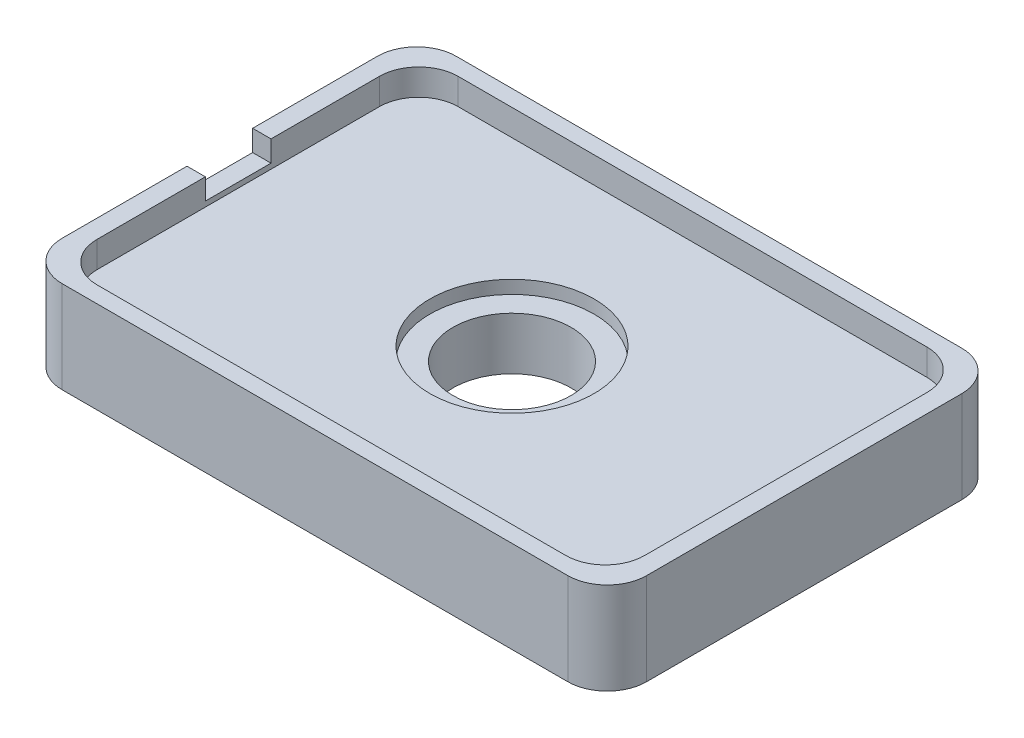
from build123d import *

# Parameters (mm, degrees)
SKETCH1_W           = 44.5
SKETCH1_H           = 30
BOSS_EXTRUDE1_DEPTH = 5
CUT_EXTRUDE1_REACH  = 7
SKETCH2_R           = 4.5
SKETCH5_W           = 44.5
SKETCH5_H           = 30
SKETCH5_W_2         = 41.7
SKETCH5_H_2         = 27.5
BOSS_EXTRUDE2_DEPTH = 2
CUT_EXTRUDE5_REACH  = 46.5
SKETCH6_W           = 5
SKETCH6_H           = 1.6
FILLET1_R           = 3
SKETCH7_R           = 6.25
CUT_EXTRUDE6_DEPTH  = 1


with BuildPart() as part:
    # Sketch1 → Boss-Extrude1 (new body)
    with BuildSketch(Plane(origin=(0, 0, 0), x_dir=(1, 0, 0), z_dir=(0, 1, 0))):
        Rectangle(SKETCH1_W, SKETCH1_H)
    extrude(amount=-BOSS_EXTRUDE1_DEPTH)

    # Sketch2 → Cut-Extrude1 (cut, up to next)
    with BuildSketch(Plane(origin=(0, 0, 0), x_dir=(1, 0, 0), z_dir=(0, 1, 0)), mode=Mode.PRIVATE) as cut_extrude1_sk1:
        Circle(SKETCH2_R)
    cut_extrude1_tool1 = extrude(cut_extrude1_sk1.sketch, amount=-CUT_EXTRUDE1_REACH, mode=Mode.PRIVATE) & part.part
    add(cut_extrude1_tool1.solids().sort_by_distance((0, 0, 0))[0], mode=Mode.SUBTRACT)

    # Sketch5 → Boss-Extrude2 (add)
    with BuildSketch(Plane(origin=(0, 0, 0), x_dir=(1, 0, 0), z_dir=(0, 1, 0))):
        Rectangle(SKETCH5_W, SKETCH5_H)
        Rectangle(SKETCH5_W_2, SKETCH5_H_2, mode=Mode.SUBTRACT)
    extrude(amount=BOSS_EXTRUDE2_DEPTH)

    # Sketch6 → Cut-Extrude5 (cut, up to next)
    with BuildSketch(Plane.ZY.offset(22.25), mode=Mode.PRIVATE) as cut_extrude5_sk1:
        with Locations((0, 1.2)):
            Rectangle(SKETCH6_W, SKETCH6_H)
    cut_extrude5_tool1 = extrude(cut_extrude5_sk1.sketch, amount=-CUT_EXTRUDE5_REACH, mode=Mode.PRIVATE) & part.part
    add(cut_extrude5_tool1.solids().sort_by_distance((-22.25, 1.2, 0))[0], mode=Mode.SUBTRACT)

    # Fillet1
    fillet1_edges = [part.edges().sort_by_distance(p)[0] for p in [
        (-20.85, 1, 13.75),
        (20.85, 1, 13.75),
        (20.85, 1, -13.75),
        (-20.85, 1, -13.75),
        (22.25, -1.5, 15),
        (-22.25, -1.5, 15),
        (-22.25, -1.5, -15),
        (22.25, -1.5, -15),
    ]]
    fillet(fillet1_edges, radius=FILLET1_R)

    # Sketch7 → Cut-Extrude6 (cut)
    with BuildSketch(Plane(origin=(0, 0, 0), x_dir=(1, 0, 0), z_dir=(0, 1, 0))):
        Circle(SKETCH7_R)
    extrude(amount=-CUT_EXTRUDE6_DEPTH, mode=Mode.SUBTRACT)


solid = part.part
